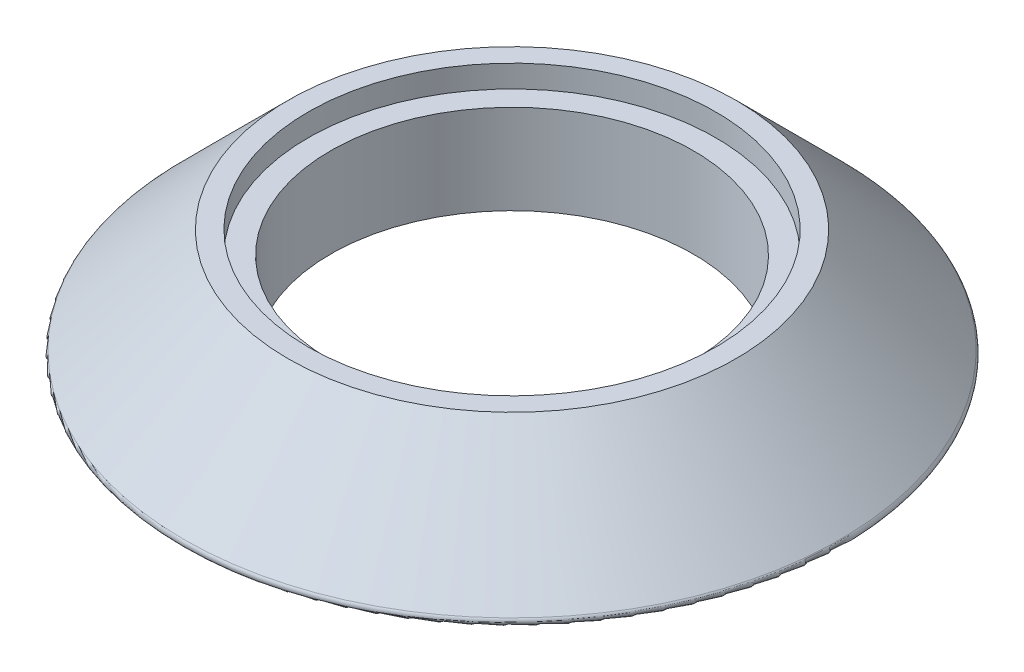
from build123d import *

# Parameters (mm, degrees)
SKETCH_1_R          = 10
SKETCH_1_R_2        = 8.1
EXTRUDE_1_DEPTH     = 5
FILLET_1_R          = 0.2
SKETCH_3_R          = 9.1
CUT_EXTRUDE_1_DEPTH = 1


with BuildPart() as part:
    # 草图1 → 凸台-拉伸1 (new body)
    with BuildSketch(Plane(origin=(0, 0, 0), x_dir=(1, 0, 0), z_dir=(0, 1, 0))):
        Circle(SKETCH_1_R)
        Circle(SKETCH_1_R_2, mode=Mode.SUBTRACT)
    extrude(amount=EXTRUDE_1_DEPTH)

    # 草图2 → 旋转1 (revolve)
    with BuildSketch(Plane(origin=(0, 0, 0), x_dir=(0, 0, -1), z_dir=(1, 0, 0))):
        Polygon((10, 5), (10, 0), (15, 0), align=None)
    revolve(axis=Axis((0, 0, 0), (0, 1, 0)))

    # 圆角1
    fillet_1_edges = [part.edges().sort_by_distance(p)[0] for p in [
        (0, 0, 15),
    ]]
    fillet(fillet_1_edges, radius=FILLET_1_R)

    # 草图3 → 切除-拉伸1 (cut)
    with BuildSketch(Plane(origin=(0, 5, 0), x_dir=(1, 0, 0), z_dir=(0, 1, 0))):
        Circle(SKETCH_3_R)
    extrude(amount=-CUT_EXTRUDE_1_DEPTH, mode=Mode.SUBTRACT)


solid = part.part
